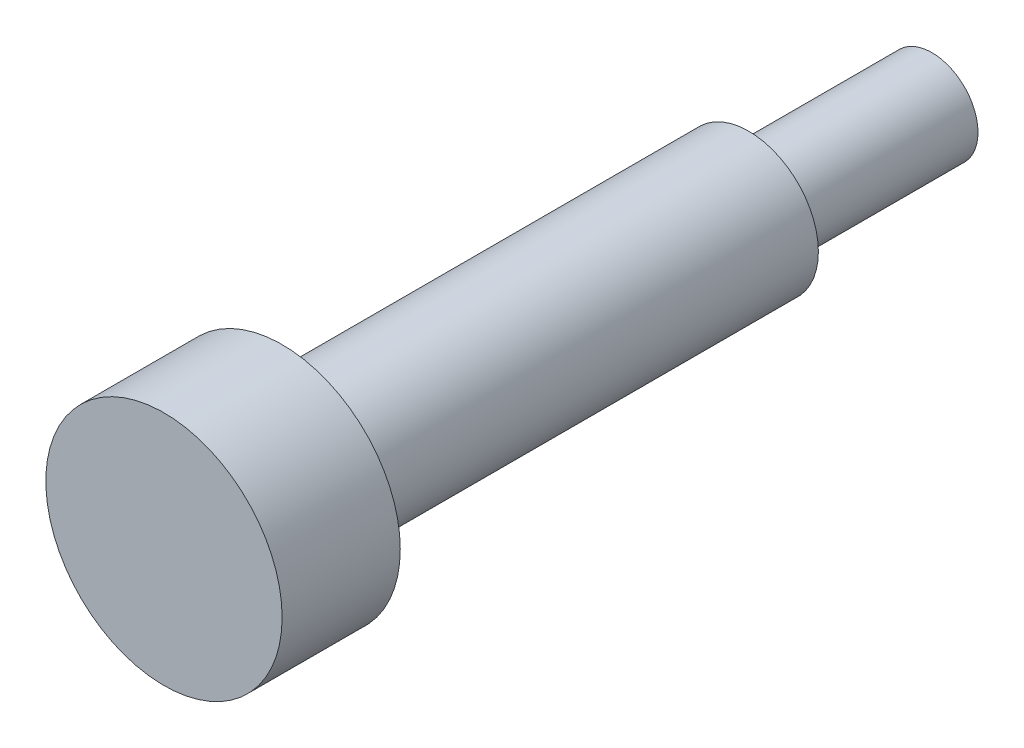
from build123d import *

# Parameters (mm, degrees)
SKETCH1_R           = 1.9808444
BOSS_EXTRUDE1_DEPTH = 7.874
SKETCH2_R           = 1.143
CUT_EXTRUDE2_DEPTH  = 8.874
SKETCH3_R           = 2.99147738
BOSS_EXTRUDE2_DEPTH = 20.066
SKETCH4_R           = 5.08
BOSS_EXTRUDE3_DEPTH = 5.08


with BuildPart() as part:
    # Sketch1 → Boss-Extrude1 (new body)
    with BuildSketch(Plane.XY):
        Circle(SKETCH1_R)
    extrude(amount=BOSS_EXTRUDE1_DEPTH)

    # Sketch2 → Cut-Extrude2 (cut, through all)
    with BuildSketch(Plane(origin=(0, 0, 0), x_dir=(-1, 0, 0), z_dir=(0, 0, -1))):
        Circle(SKETCH2_R)
    extrude(amount=-CUT_EXTRUDE2_DEPTH, mode=Mode.SUBTRACT)

    # Sketch3 → Boss-Extrude2 (add)
    with BuildSketch(Plane.XY.offset(7.874)):
        Circle(SKETCH3_R)
    extrude(amount=BOSS_EXTRUDE2_DEPTH)

    # Sketch4 → Boss-Extrude3 (add)
    with BuildSketch(Plane.XY.offset(27.94)):
        Circle(SKETCH4_R)
    extrude(amount=BOSS_EXTRUDE3_DEPTH)


solid = part.part
